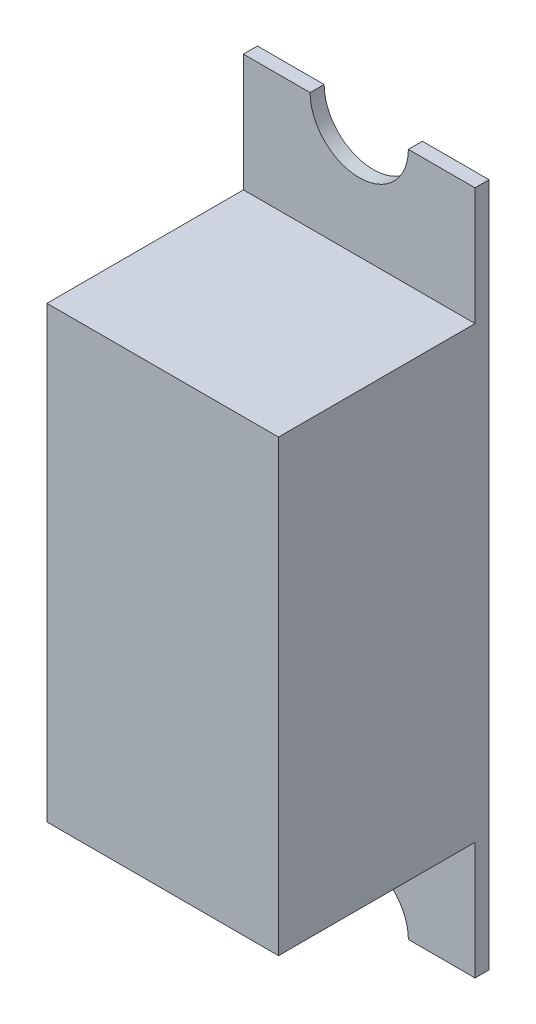
from build123d import *

# Parameters (mm, degrees)
ESQUISSE1_W        = 6.6
ESQUISSE1_H        = 12.8
BOSS_EXTRU_1_DEPTH = 5.6
ESQUISSE2_W        = 1.9
ESQUISSE2_H        = 12.8
ESQUISSE2_W_2      = 2.8
ESQUISSE2_H_2      = 3.35
BOSS_EXTRU_2_DEPTH = 0.4


with BuildPart() as part:
    # Esquisse1 → Boss.-Extru.1 (new body)
    with BuildSketch(Plane.XY):
        with Locations((-3.3, -6.4)):
            Rectangle(ESQUISSE1_W, ESQUISSE1_H)
    extrude(amount=BOSS_EXTRU_1_DEPTH)

    # Esquisse2 → Boss.-Extru.2 (add)
    with BuildSketch(Plane(origin=(0, 0, 0), x_dir=(-1, 0, 0), z_dir=(0, 0, -1))):
        with Locations((0.95, -6.4)):
            Rectangle(ESQUISSE2_W, ESQUISSE2_H)
        with Locations((3.3, -6.4)):
            Rectangle(ESQUISSE2_W_2, ESQUISSE2_H)
        with Locations((5.65, -6.4)):
            Rectangle(ESQUISSE2_W, ESQUISSE2_H)
        with Locations((0.95, -14.475)):
            Rectangle(ESQUISSE2_W, ESQUISSE2_H_2)
        with BuildLine():
            Line((4.7, -12.8), (1.9, -12.8))
            Line((1.9, -12.8), (1.9, -16.15))
            ThreePointArc((1.9, -16.15), (3.3, -14.75), (4.7, -16.15))
            Line((4.7, -16.15), (4.7, -12.8))
        make_face()
        with Locations((5.65, -14.475)):
            Rectangle(ESQUISSE2_W, ESQUISSE2_H_2)
        with Locations((0.95, 1.675)):
            Rectangle(ESQUISSE2_W, ESQUISSE2_H_2)
        with BuildLine():
            ThreePointArc((4.7, 3.35), (3.3, 1.95), (1.9, 3.35))
            Line((1.9, 3.35), (1.9, 0))
            Line((1.9, 0), (4.7, 0))
            Line((4.7, 0), (4.7, 3.35))
        make_face()
        with Locations((5.65, 1.675)):
            Rectangle(ESQUISSE2_W, ESQUISSE2_H_2)
    extrude(amount=BOSS_EXTRU_2_DEPTH)


solid = part.part
